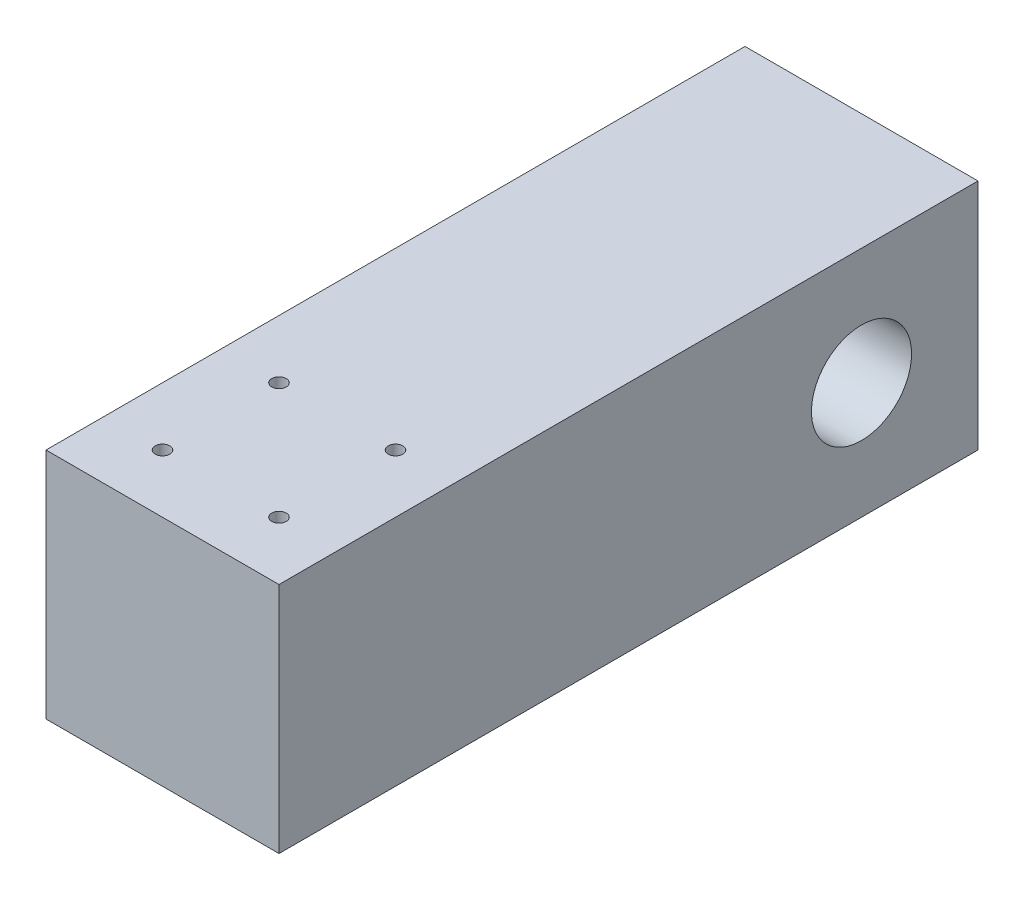
from build123d import *

# Parameters (mm, degrees)
SKETCH1_W           = 152.4
SKETCH1_H           = 50.8
BOSS_EXTRUDE1_DEPTH = 50.8
SKETCH2_R           = 10.9140625
CUT_EXTRUDE1_DEPTH  = 51.8
SKETCH3_R           = 1.5875
CUT_EXTRUDE2_DEPTH  = 51.8


with BuildPart() as part:
    # Sketch1 → Boss-Extrude1 (new body)
    with BuildSketch(Plane(origin=(0, 0, 0), x_dir=(0, 0, -1), z_dir=(1, 0, 0))):
        with Locations((76.2, 25.4)):
            Rectangle(SKETCH1_W, SKETCH1_H)
    extrude(amount=BOSS_EXTRUDE1_DEPTH)

    # Sketch2 → Cut-Extrude1 (cut, through all)
    with BuildSketch(Plane(origin=(50.8, 0, 0), x_dir=(0, 0, -1), z_dir=(1, 0, 0))):
        with Locations((127, 25.4)):
            Circle(SKETCH2_R)
    extrude(amount=-CUT_EXTRUDE1_DEPTH, mode=Mode.SUBTRACT)

    # Sketch3 → Cut-Extrude2 (cut, through all)
    with BuildSketch(Plane(origin=(0, 50.8, 0), x_dir=(1, 0, 0), z_dir=(0, 1, 0))):
        with Locations((12.7, 38.1)):
            Circle(SKETCH3_R)
        with Locations((38.1, 38.1)):
            Circle(SKETCH3_R)
        with Locations((12.7, 12.7)):
            Circle(SKETCH3_R)
        with Locations((38.1, 12.7)):
            Circle(SKETCH3_R)
    extrude(amount=-CUT_EXTRUDE2_DEPTH, mode=Mode.SUBTRACT)


solid = part.part
